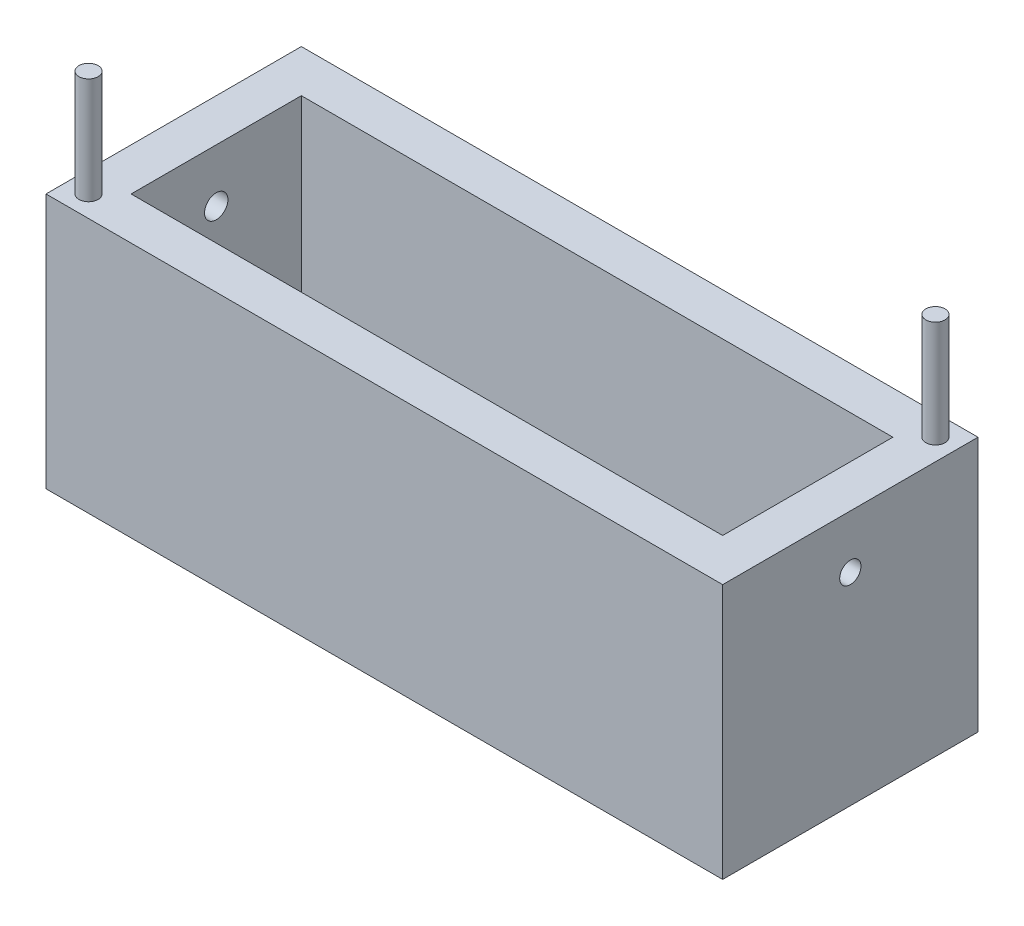
from build123d import *

# Parameters (mm, degrees)
SKETCH1_W           = 403.86
SKETCH1_H           = 152.4
BOSS_EXTRUDE1_DEPTH = 152.4
SKETCH3_W           = 353.06
SKETCH3_H           = 101.6
CUT_EXTRUDE1_DEPTH  = 139.7
SKETCH4_R           = 5.715
BOSS_EXTRUDE2_DEPTH = 63.5
SKETCH5_R           = 6.35
CUT_EXTRUDE2_DEPTH  = 63.5
CUT_EXTRUDE3_REACH  = 405.86
SKETCH6_R           = 6.985
SKETCH7_R           = 5.715
BOSS_EXTRUDE3_DEPTH = 63.5


with BuildPart() as part:
    # Sketch1 → Boss-Extrude1 (new body)
    with BuildSketch(Plane.XY):
        with Locations((-201.93, 76.2)):
            Rectangle(SKETCH1_W, SKETCH1_H)
    extrude(amount=BOSS_EXTRUDE1_DEPTH)

    # Sketch3 → Cut-Extrude1 (cut)
    with BuildSketch(Plane(origin=(0, 152.4, 0), x_dir=(1, 0, 0), z_dir=(0, 1, 0))):
        with Locations((-201.93, -76.2)):
            Rectangle(SKETCH3_W, SKETCH3_H)
    extrude(amount=-CUT_EXTRUDE1_DEPTH, mode=Mode.SUBTRACT)

    # Sketch4 → Boss-Extrude2 (add)
    with BuildSketch(Plane(origin=(0, 152.4, 0), x_dir=(1, 0, 0), z_dir=(0, 1, 0))):
        with Locations((-391.16, -139.7)):
            Circle(SKETCH4_R)
    extrude(amount=BOSS_EXTRUDE2_DEPTH)

    # Sketch5 → Cut-Extrude2 (cut)
    with BuildSketch(Plane(origin=(0, 0, 0), x_dir=(0, 0, -1), z_dir=(1, 0, 0))):
        with Locations((-76.2, 120.65)):
            Circle(SKETCH5_R)
    extrude(amount=-CUT_EXTRUDE2_DEPTH, mode=Mode.SUBTRACT)

    # Sketch6 → Cut-Extrude3 (cut, up to next)
    with BuildSketch(Plane.ZY.offset(403.86), mode=Mode.PRIVATE) as cut_extrude3_sk1:
        with Locations((76.2, 120.65)):
            Circle(SKETCH6_R)
    cut_extrude3_tool1 = extrude(cut_extrude3_sk1.sketch, amount=-CUT_EXTRUDE3_REACH, mode=Mode.PRIVATE) & part.part
    add(cut_extrude3_tool1.solids().sort_by_distance((-403.86, 120.65, 76.2))[0], mode=Mode.SUBTRACT)

    # Sketch7 → Boss-Extrude3 (add)
    with BuildSketch(Plane(origin=(0, 152.4, 0), x_dir=(1, 0, 0), z_dir=(0, 1, 0))):
        with Locations((-12.7, -12.7)):
            Circle(SKETCH7_R)
    extrude(amount=BOSS_EXTRUDE3_DEPTH)


solid = part.part
